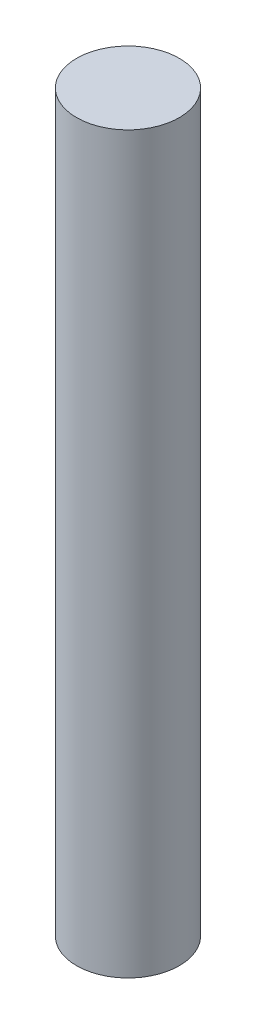
from build123d import *

# Parameters (mm, degrees)
SKETCH1_R           = 3.175
BOSS_EXTRUDE1_DEPTH = 45.3898


with BuildPart() as part:
    # Sketch1 → Boss-Extrude1 (new body)
    with BuildSketch(Plane(origin=(0, 0, 0), x_dir=(1, 0, 0), z_dir=(0, 1, 0))):
        Circle(SKETCH1_R)
    extrude(amount=BOSS_EXTRUDE1_DEPTH)


solid = part.part
